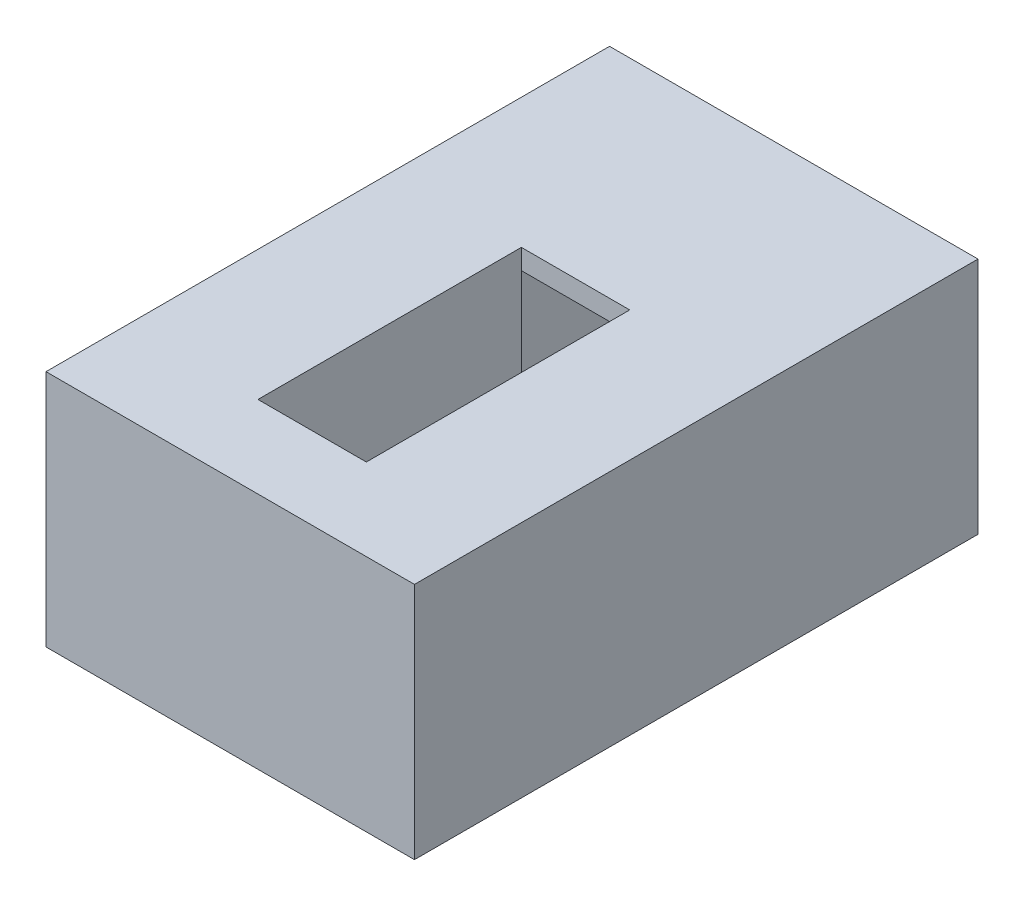
from build123d import *

# Parameters (mm, degrees)
SKETCH_1_W          = 5200
SKETCH_1_H          = 2200
EXTRUDE_1_DEPTH     = 1700
CUT_EXTRUDE_1_DEPTH = 500
SKETCH_4_W          = 1800
SKETCH_4_H          = 1694.637135117
CUT_EXTRUDE_2_DEPTH = 1000


with BuildPart() as part:
    # Эскиз1 → Бобышка-Вытянуть1 (new body, symmetric)
    with BuildSketch(Plane(origin=(0, 0, 0), x_dir=(0, 0, -1), z_dir=(1, 0, 0))):
        Rectangle(SKETCH_1_W, SKETCH_1_H)
    extrude(amount=EXTRUDE_1_DEPTH, both=True)

    # Эскиз3 → Вырез-Вытянуть1 (cut, symmetric)
    with BuildSketch(Plane(origin=(0, 0, 0), x_dir=(0, 0, -1), z_dir=(1, 0, 0))):
        Polygon((-1844.132537204, 930.267244324), (-2363.513442227, 930.267244324), (-2363.513442227, -219.732755676), (586.486557773, -219.732755676), (586.486557773, -780.268672554), (2386.486557773, -780.268672554), (2386.486557773, 914.368462563), (586.486557773, 914.368462563), (586.486557773, 1100), (-1844.132537204, 1100), align=None)
    extrude(amount=CUT_EXTRUDE_1_DEPTH, both=True, mode=Mode.SUBTRACT)

    # Эскиз4 → Вырез-Вытянуть2 (cut, symmetric)
    with BuildSketch(Plane(origin=(0, 0, 0), x_dir=(0, 0, -1), z_dir=(1, 0, 0))):
        with Locations((1486.486557773, 67.049895005)):
            Rectangle(SKETCH_4_W, SKETCH_4_H)
    extrude(amount=CUT_EXTRUDE_2_DEPTH, both=True, mode=Mode.SUBTRACT)


solid = part.part
